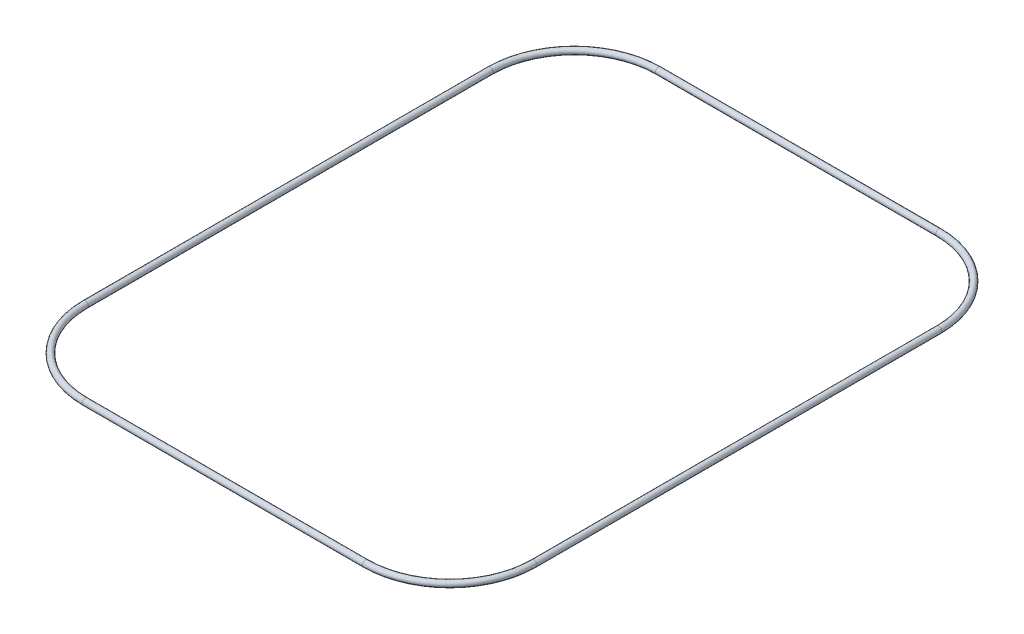
from build123d import *

# Parameters (mm, degrees)
SKETCH2_R = 0.9906


with BuildPart() as part:
    # Sweep1: sweep along a path in Sketch1
    with BuildLine(Plane(origin=(0, 0, 0), x_dir=(1, 0, 0), z_dir=(0, 1, 0))) as sweep1_path:
        Line((66.275827552, -58.889759794), (66.275827552, 71.110240206))
        ThreePointArc((66.275827552, 71.110240206), (58.355934841, 90.2305526), (39.235622447, 98.150445311))
        Line((39.235622447, 98.150445311), (-50.764377553, 98.150445311))
        ThreePointArc((-50.764377553, 98.150445311), (-69.884689947, 90.2305526), (-77.804582658, 71.110240206))
        Line((-77.804582658, 71.110240206), (-77.804582658, -58.889759794))
        ThreePointArc((-77.804582658, -58.889759794), (-69.884689947, -78.010072188), (-50.764377553, -85.929964899))
        Line((-50.764377553, -85.929964899), (39.235622447, -85.929964899))
        ThreePointArc((39.235622447, -85.929964899), (58.355934841, -78.010072188), (66.275827552, -58.889759794))
    # Sketch2 → Sweep1 (sweep)
    with BuildSketch(Plane(origin=(66.275827552, 0, -71.110240206), x_dir=(-1, 0, 0), z_dir=(0, 0, -1))):
        Circle(SKETCH2_R)
    sweep(path=sweep1_path.line)


solid = part.part
